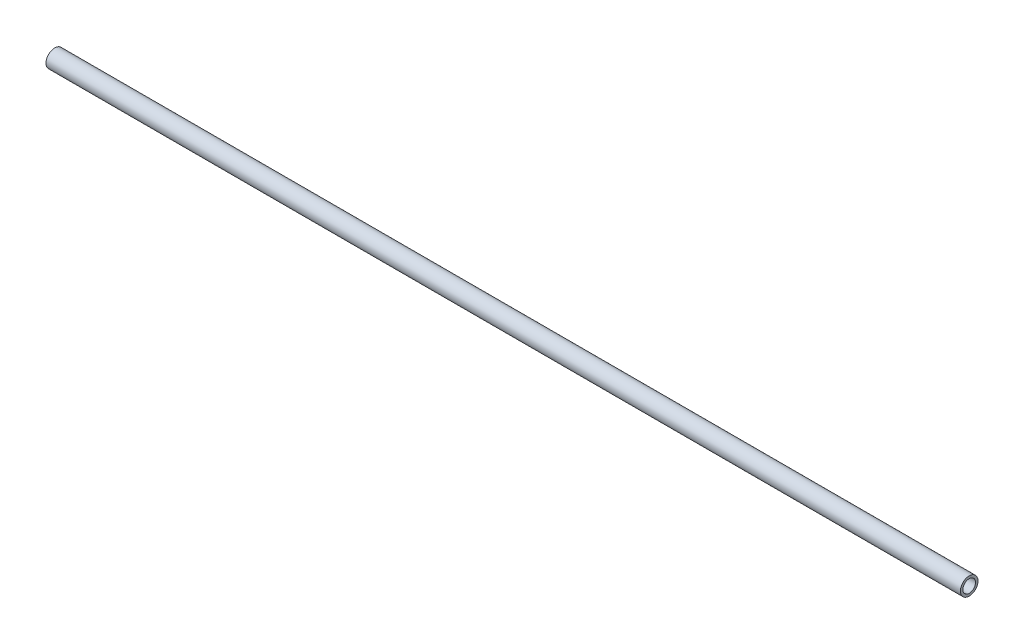
from build123d import *

# Parameters (mm, degrees)
SKETCH2_R           = 3.175
SKETCH2_R_2         = 2.286
BOSS_EXTRUDE1_DEPTH = 165.0873


with BuildPart() as part:
    # Sketch2 → Boss-Extrude1 (new body, symmetric)
    with BuildSketch(Plane(origin=(63.5, 17.527682119, 0), x_dir=(0, 0, -1), z_dir=(1, 0, 0))):
        Circle(SKETCH2_R)
        Circle(SKETCH2_R_2, mode=Mode.SUBTRACT)
    extrude(amount=BOSS_EXTRUDE1_DEPTH, both=True)


solid = part.part
